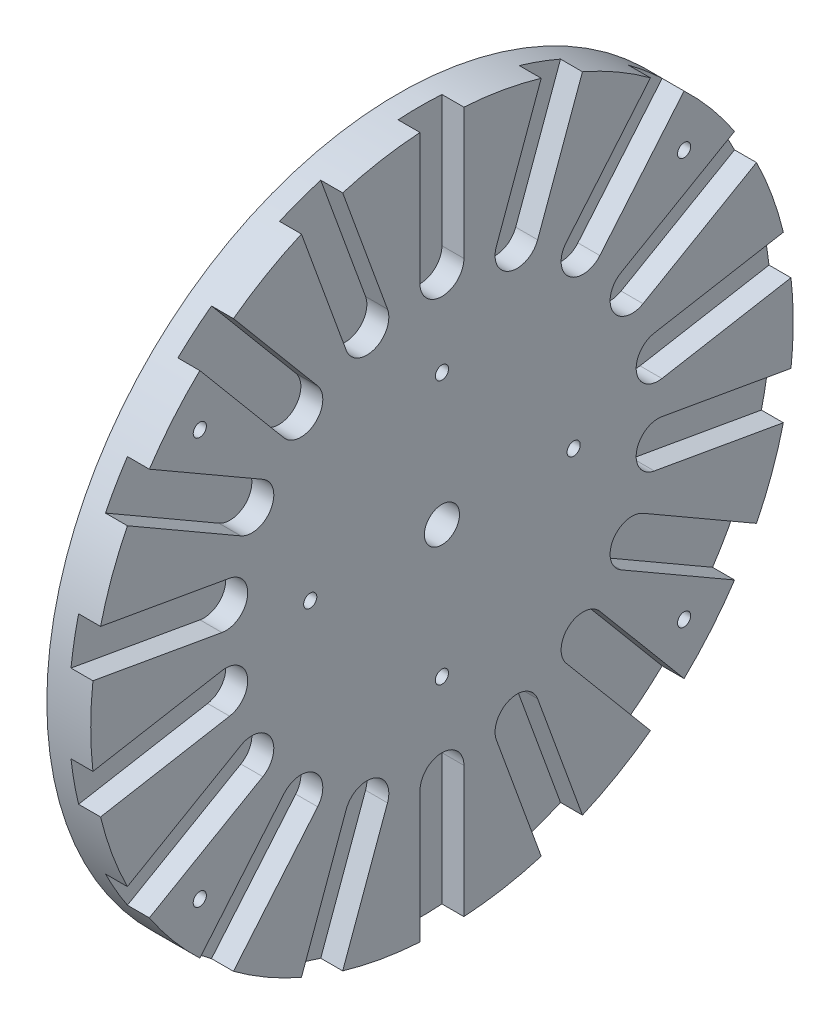
from build123d import *

# Parameters (mm, degrees)
CUT_EXTRUDE1_DEPTH = 5
CIRPATTERN1_COUNT  = 18
SKETCH4_R          = 1.5
CUT_EXTRUDE3_DEPTH = 5


with BuildPart() as part:
    # Sketch1 → Revolve2 (revolve)
    with BuildSketch(Plane.XY):
        Polygon((0, 4), (0, 80), (-10, 80), (-10, 15), (-25, 15), (-25, 4), align=None)
    revolve(axis=Axis((0, 0, 0), (-1, 0, 0)))

    # Sketch2 → Cut-Extrude1 (cut)
    with BuildSketch(Plane(origin=(0, 0, 0), x_dir=(0, 0, -1), z_dir=(1, 0, 0))):
        with BuildLine():
            Line((5, 50), (5, 80))
            Line((5, 80), (-5, 80))
            Line((-5, 80), (-5, 50))
            ThreePointArc((-5, 50), (0, 45), (5, 50))
        make_face()
    cut_extrude1 = extrude(amount=-CUT_EXTRUDE1_DEPTH, mode=Mode.SUBTRACT)

    # CirPattern1: Cut-Extrude1 ×18 about axis
    cirpattern1_axis = Axis((0, 0, 0), (1, 0, 0))
    for i in range(1, CIRPATTERN1_COUNT):
        add(cut_extrude1.rotate(cirpattern1_axis, i * 360 / CIRPATTERN1_COUNT), mode=Mode.SUBTRACT)

    # Sketch4 → Cut-Extrude3 (cut)
    with BuildSketch(Plane(origin=(0, 0, 0), x_dir=(0, 0, -1), z_dir=(1, 0, 0))):
        with Locations((-55.155199905, 46.280707897)):
            Circle(SKETCH4_R)
        with Locations((55.155199905, 46.280707897)):
            Circle(SKETCH4_R)
        with Locations((55.155199905, -46.280707897)):
            Circle(SKETCH4_R)
        with Locations((-55.155199905, -46.280707897)):
            Circle(SKETCH4_R)
        with Locations((0, 30)):
            Circle(SKETCH4_R)
        with Locations((30, 0)):
            Circle(SKETCH4_R)
        with Locations((0, -30)):
            Circle(SKETCH4_R)
        with Locations((-30, 0)):
            Circle(SKETCH4_R)
    extrude(amount=-CUT_EXTRUDE3_DEPTH, mode=Mode.SUBTRACT)


solid = part.part
